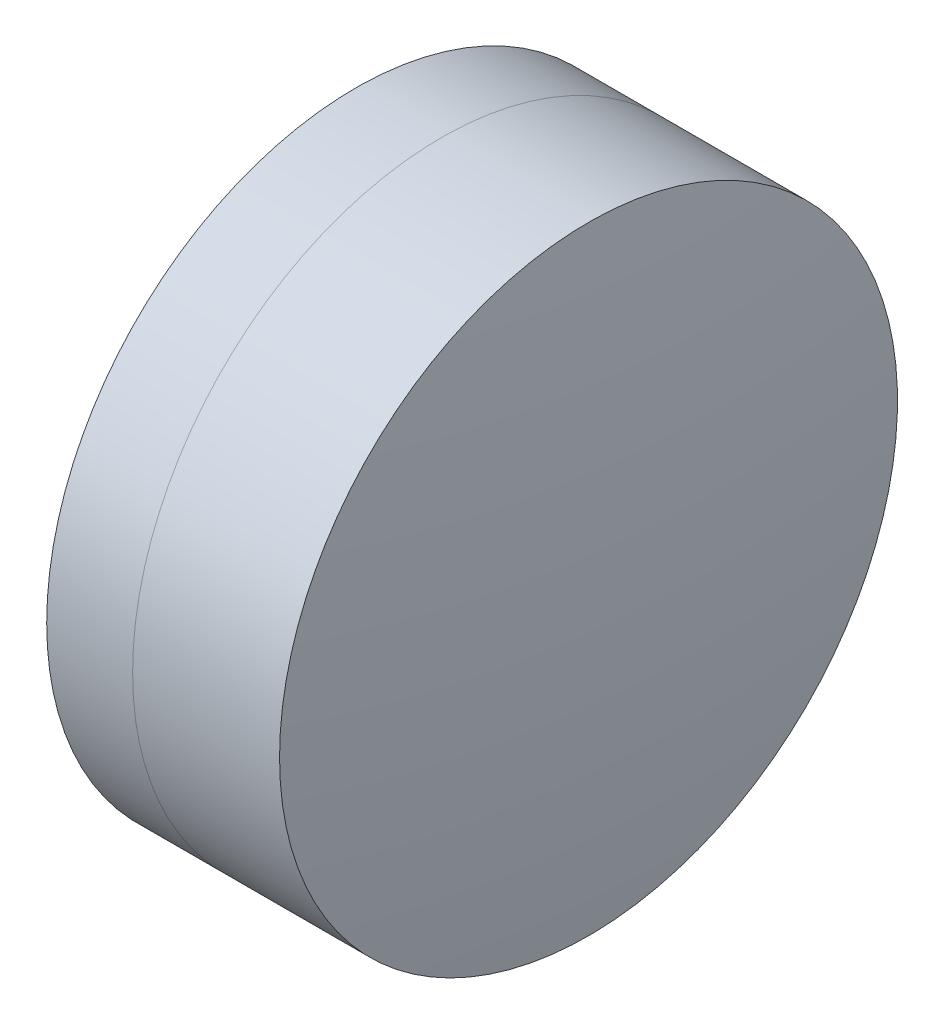
from build123d import *


with BuildPart() as part:
    # 草图1 one side → 旋转1 (revolve)
    with BuildSketch(Plane(origin=(0, 0, 0), x_dir=(1, 0, 0), z_dir=(0, 1, 0)), mode=Mode.PRIVATE) as revolve_1_sk:
        with BuildLine():
            ThreePointArc((218.877733484, 12.7), (216.168950276, 6.605061901), (215.242163258, 0))
            Line((215.242163258, 0), (227.242163258, 0))
            ThreePointArc((227.242163258, 0), (225.992813565, 6.794430338), (222.408206858, 12.7))
            Line((222.408206858, 12.7), (218.877733484, 12.7))
        make_face()
    revolve(revolve_1_sk.sketch.rotate(Axis((-9.702612178, 0, 0), (1, 0, 0)), 180), axis=Axis((-9.702612178, 0, 0), (1, 0, 0)))  # turned: the seam where the file's is


with BuildPart() as body_2:
    # 草图2 one side → 旋转3 (revolve)
    with BuildSketch(Plane(origin=(0, 0, 0), x_dir=(1, 0, 0), z_dir=(0, 1, 0)), mode=Mode.PRIVATE) as revolve_3_sk:
        with BuildLine():
            Line((228.449221255, 12.7), (222.408206858, 12.7))
            ThreePointArc((222.408206858, 12.7), (225.992813565, 6.794430338), (227.242163258, 0))
            Line((227.242163258, 0), (229.242163258, 0))
            ThreePointArc((229.242163258, 0), (229.043734937, 6.362365068), (228.449221255, 12.7))
        make_face()
    revolve(revolve_3_sk.sketch.rotate(Axis((-0.551919993, 0, 0), (1, 0, 0)), 180), axis=Axis((-0.551919993, 0, 0), (1, 0, 0)))  # turned: the seam where the file's is


solid = Compound([part.part, body_2.part])
